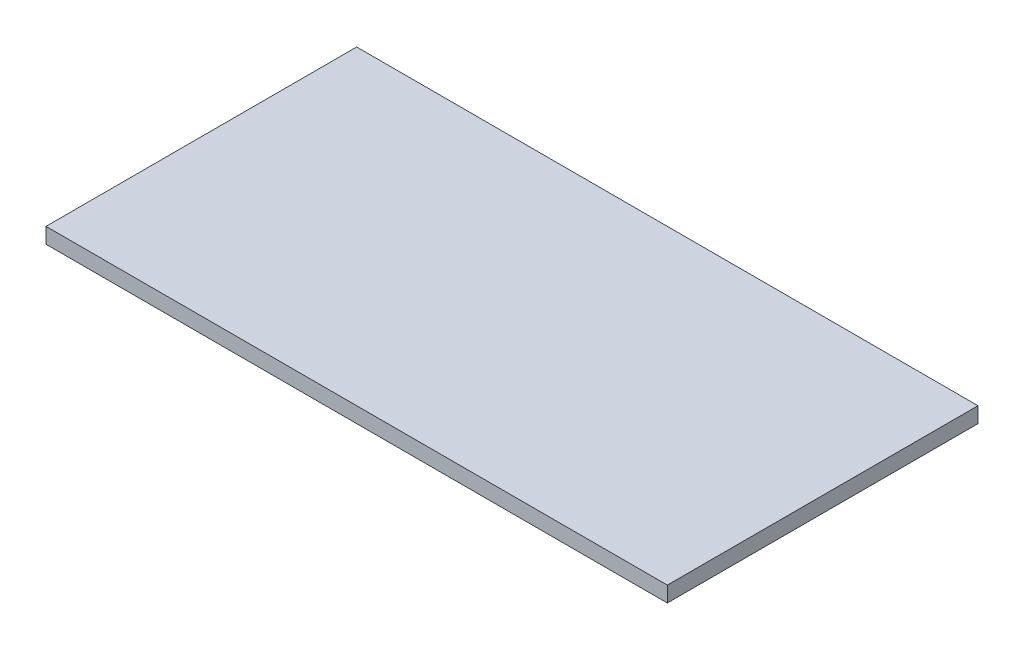
from build123d import *

# Parameters (mm, degrees)
SKETCH1_W           = 254
SKETCH1_H           = 127
BOSS_EXTRUDE1_DEPTH = 6.35


with BuildPart() as part:
    # Sketch1 → Boss-Extrude1 (new body)
    with BuildSketch(Plane(origin=(0, 0, 0), x_dir=(1, 0, 0), z_dir=(0, 1, 0))):
        with Locations((127, 63.5)):
            Rectangle(SKETCH1_W, SKETCH1_H)
    extrude(amount=BOSS_EXTRUDE1_DEPTH)


solid = part.part
